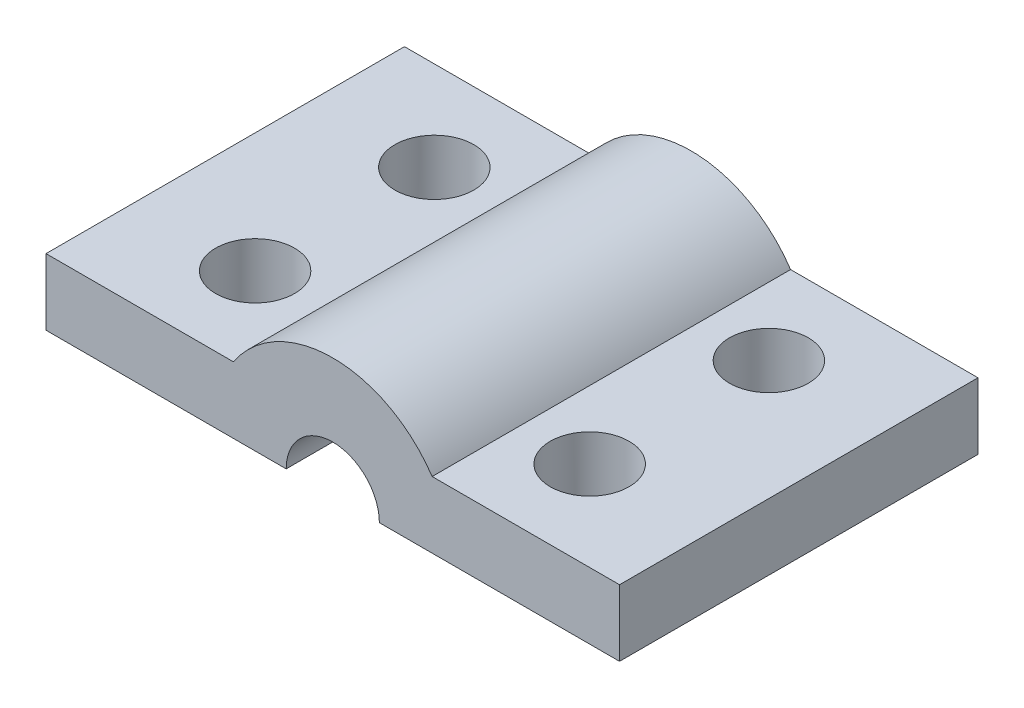
from build123d import *

# Parameters (mm, degrees)
BOSS_EXTRUDE1_DEPTH     = 7.5
SKETCH2_R               = 1.65
CUT_EXTRUDE1_DEPTH      = 15.420976523
MIRROR2_COPY_1_SKETCH_R = 1.65
MIRROR2_COPY_1_DEPTH    = 15.420976523


with BuildPart() as part:
    # Sketch1 → Boss-Extrude1 (new body)
    with BuildSketch(Plane.XY):
        with BuildLine():
            Line((-12, 0), (-5, 0))
            ThreePointArc((-5, 0), (-4.784761162, 1.451227281), (-4.157575752, 2.777510373))
            Line((-4.157575752, 2.777510373), (-12, 2.777510373))
            Line((-12, 2.777510373), (-12, 0))
        make_face()
        with BuildLine():
            ThreePointArc((-4.157575752, 2.777510373), (-4.784761162, 1.451227281), (-5, 0))
            Line((-5, 0), (-1.95, 0))
            ThreePointArc((-1.95, 0), (-1.378858223, 1.378858223), (0, 1.95))
            Line((0, 1.95), (0, 5))
            ThreePointArc((0, 5), (-2.357164413, 4.409509716), (-4.157575752, 2.777510373))
        make_face()
        with BuildLine():
            Line((1.95, 0), (5, 0))
            ThreePointArc((5, 0), (4.784761162, 1.451227281), (4.157575752, 2.777510373))
            ThreePointArc((4.157575752, 2.777510373), (2.357164413, 4.409509716), (0, 5))
            Line((0, 5), (0, 1.95))
            ThreePointArc((0, 1.95), (1.378858223, 1.378858223), (1.95, 0))
        make_face()
        with BuildLine():
            ThreePointArc((4.157575752, 2.777510373), (4.784761162, 1.451227281), (5, 0))
            Line((5, 0), (12, 0))
            Line((12, 0), (12, 2.777510373))
            Line((12, 2.777510373), (4.157575752, 2.777510373))
        make_face()
    boss_extrude1 = extrude(amount=BOSS_EXTRUDE1_DEPTH)

    # Sketch2 → Cut-Extrude1 (cut, symmetric)
    with BuildSketch(Plane(origin=(0, 2.777510373, 0), x_dir=(1, 0, 0), z_dir=(0, 1, 0))):
        with Locations(Location((-7, -3.75, 0), (0, 0, 270))):
            Circle(SKETCH2_R)
    cut_extrude1 = extrude(amount=CUT_EXTRUDE1_DEPTH, both=True, mode=Mode.SUBTRACT)

    # Mirror1: Cut-Extrude1 across plane
    add(cut_extrude1.mirror(Plane(origin=(0, 0, 0), x_dir=(0, 0, 1), z_dir=(1, 0, 0))), mode=Mode.SUBTRACT)

    # Mirror2: Boss-Extrude1, Cut-Extrude1 across plane
    add(boss_extrude1.mirror(Plane.XY))
    add(cut_extrude1.mirror(Plane.XY), mode=Mode.SUBTRACT)

    # Mirror2 copy 1 sketch → Mirror2 copy 1 (cut, symmetric)
    with BuildSketch(Plane(origin=(0, 2.777510373, 0), x_dir=(-1, 0, 0), z_dir=(0, 1, 0))):
        with Locations(Location((-7, -3.75, 0), (0, 0, 270))):
            Circle(MIRROR2_COPY_1_SKETCH_R)
    extrude(amount=MIRROR2_COPY_1_DEPTH, both=True, mode=Mode.SUBTRACT)


solid = part.part
